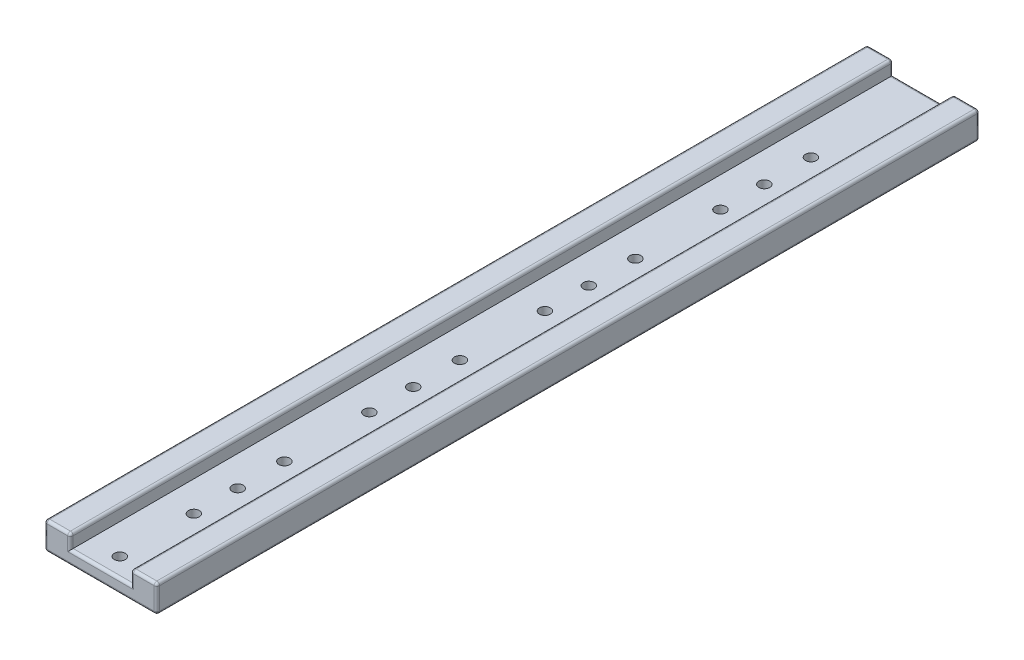
from build123d import *

# Parameters (mm, degrees)
BOSS_EXTRUDE1_DEPTH = 300
SKETCH2_R           = 2
CUT_EXTRUDE1_DEPTH  = 5
FILLET1_R           = 1
FILLET2_R           = 1


with BuildPart() as part:
    # Sketch1 → Boss-Extrude1 (new body)
    with BuildSketch(Plane.XY):
        Polygon((-11, 5), (-11, 0), (11, 0), (11, 5), (20.5, 5), (20.5, -5), (-20.5, -5), (-20.5, 5), align=None)
    extrude(amount=BOSS_EXTRUDE1_DEPTH)

    # Sketch2 → Cut-Extrude1 (cut)
    with BuildSketch(Plane.XZ.offset(5)):
        with Locations((-14.5, 293)):
            Circle(SKETCH2_R)
        with Locations((0, 293)):
            Circle(SKETCH2_R)
        with Locations((14.5, 293)):
            Circle(SKETCH2_R)
        with Locations((0, 266)):
            Circle(SKETCH2_R)
        with Locations((0, 250)):
            Circle(SKETCH2_R)
        with Locations((0, 233)):
            Circle(SKETCH2_R)
        with Locations((0, 169)):
            Circle(SKETCH2_R)
        with Locations((0, 105)):
            Circle(SKETCH2_R)
        with Locations((0, 186)):
            Circle(SKETCH2_R)
        with Locations((0, 122)):
            Circle(SKETCH2_R)
        with Locations((0, 202)):
            Circle(SKETCH2_R)
        with Locations((0, 138)):
            Circle(SKETCH2_R)
        with Locations((0, 74)):
            Circle(SKETCH2_R)
        with Locations((0, 58)):
            Circle(SKETCH2_R)
        with Locations((0, 41)):
            Circle(SKETCH2_R)
    extrude(amount=-CUT_EXTRUDE1_DEPTH, mode=Mode.SUBTRACT)

    # Fillet1
    fillet1_edges = [part.edges().sort_by_distance(p)[0] for p in [
        (20.5, 5, 150),
        (20.5, -5, 150),
        (-20.5, -5, 150),
        (-20.5, 5, 150),
        (-11, 5, 150),
        (11, 5, 150),
    ]]
    fillet(fillet1_edges, radius=FILLET1_R)

    # Fillet2
    fillet2_edges = [part.edges().sort_by_distance(p)[0] for p in [
        (0, 0, 300),
        (20.207106781, -4.707106781, 300),
        (-11.292893219, 4.707106781, 300),
        (11.292893219, 4.707106781, 300),
        (-11, 2, 300),
        (11, 2, 0),
        (11, 2, 300),
        (15.75, 5, 0),
        (20.5, 0, 0),
        (0, -5, 0),
        (-20.5, 0, 0),
        (-15.75, 5, 0),
        (20.207106781, 4.707106781, 0),
        (-20.207106781, 4.707106781, 0),
        (-20.207106781, -4.707106781, 0),
        (20.207106781, -4.707106781, 0),
        (-11, 2, 0),
        (-11.292893219, 4.707106781, 0),
        (11.292893219, 4.707106781, 0),
        (15.75, 5, 300),
        (-15.75, 5, 300),
        (-20.5, 0, 300),
        (0, 0, 0),
        (0, -5, 300),
        (20.5, 0, 300),
        (20.207106781, 4.707106781, 300),
        (-20.207106781, 4.707106781, 300),
        (-20.207106781, -4.707106781, 300),
    ]]
    fillet(fillet2_edges, radius=FILLET2_R)


solid = part.part
